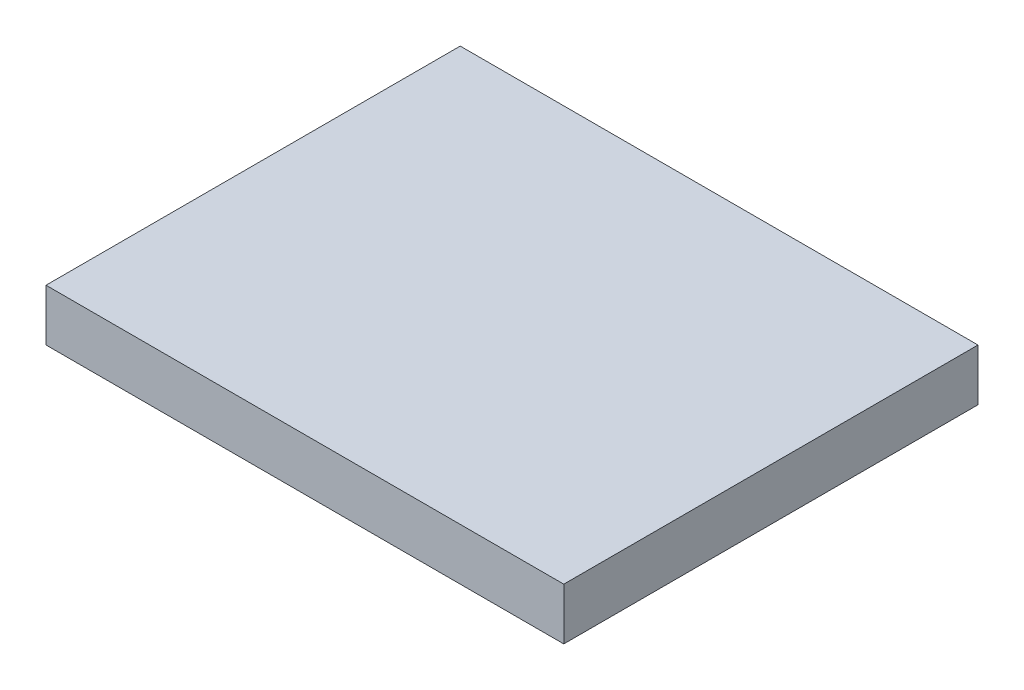
from build123d import *

# Parameters (mm, degrees)
SCHIZZO1_W                   = 100
SCHIZZO1_H                   = 80
ESTRUSIONE_ESTRUSIONE1_DEPTH = 10


with BuildPart() as part:
    # Schizzo1 → Estrusione-Estrusione1 (new body)
    with BuildSketch(Plane(origin=(0, 0, 0), x_dir=(1, 0, 0), z_dir=(0, 1, 0))):
        with Locations((50, -40)):
            Rectangle(SCHIZZO1_W, SCHIZZO1_H)
    extrude(amount=ESTRUSIONE_ESTRUSIONE1_DEPTH)


solid = part.part
